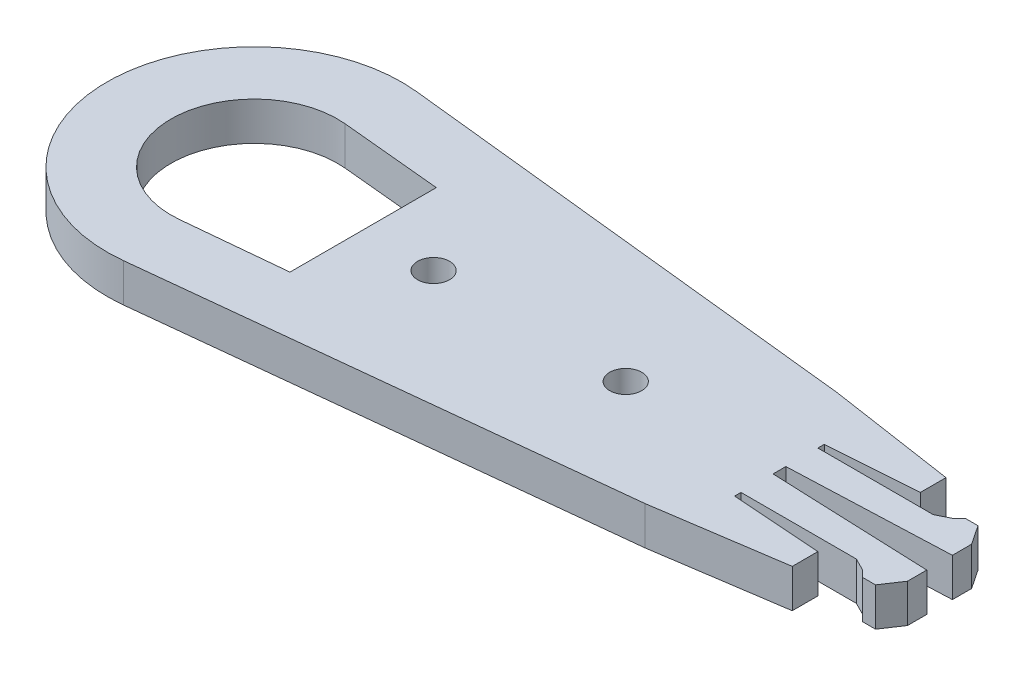
from build123d import *

# Parameters (mm, degrees)
SKETCH1_R           = 1.25
BOSS_EXTRUDE1_DEPTH = 3


with BuildPart() as part:
    # Sketch1 → Boss-Extrude1 (new body)
    with BuildSketch(Plane(origin=(0, 0, 0), x_dir=(1, 0, 0), z_dir=(0, 1, 0))):
        with BuildLine():
            Line((48, -6), (38, -7.5))
            Line((38, -7.5), (1.223406601, -11.434739887))
            ThreePointArc((1.223406601, -11.434739887), (-11.5, 0), (1.223406601, 11.434739887))
            Line((1.223406601, 11.434739887), (38, 7.5))
            Line((38, 7.5), (48, 6))
            Line((48, 6), (48, 4))
            Line((48, 4), (41, 3.5))
            Line((41, 3.5), (41, 3))
            Line((41, 3), (50, 3))
            Line((50, 3), (51, 3.5))
            Line((51, 3.5), (51.5, 4))
            Line((51.5, 4), (52.5, 4))
            Line((52.5, 4), (53.5, 2.5))
            Line((53.5, 2.5), (53.5, 1))
            Line((53.5, 1), (41, 0.5))
            Line((41, 0.5), (41, -0.5))
            Line((41, -0.5), (53.5, -1))
            Line((53.5, -1), (53.5, -2.5))
            Line((53.5, -2.5), (52.5, -4))
            Line((52.5, -4), (51.5, -4))
            Line((51.5, -4), (51, -3.5))
            Line((51, -3.5), (50, -3))
            Line((50, -3), (41, -3))
            Line((41, -3), (41, -3.5))
            Line((41, -3.5), (48, -4))
            Line((48, -4), (48, -6))
        make_face()
        with Locations((29, 0)):
            Circle(SKETCH1_R, mode=Mode.SUBTRACT)
        with Locations((14, 0)):
            Circle(SKETCH1_R, mode=Mode.SUBTRACT)
        with BuildLine():
            ThreePointArc((0.622997391, 6.470075289), (-6.5, 0), (0.622997391, -6.470075289))
            Line((0.622997391, -6.470075289), (8.5, -5.711606206))
            Line((8.5, -5.711606206), (8.5, 5.711606206))
            Line((8.5, 5.711606206), (0.622997391, 6.470075289))
        make_face(mode=Mode.SUBTRACT)
    extrude(amount=-BOSS_EXTRUDE1_DEPTH)


solid = part.part
